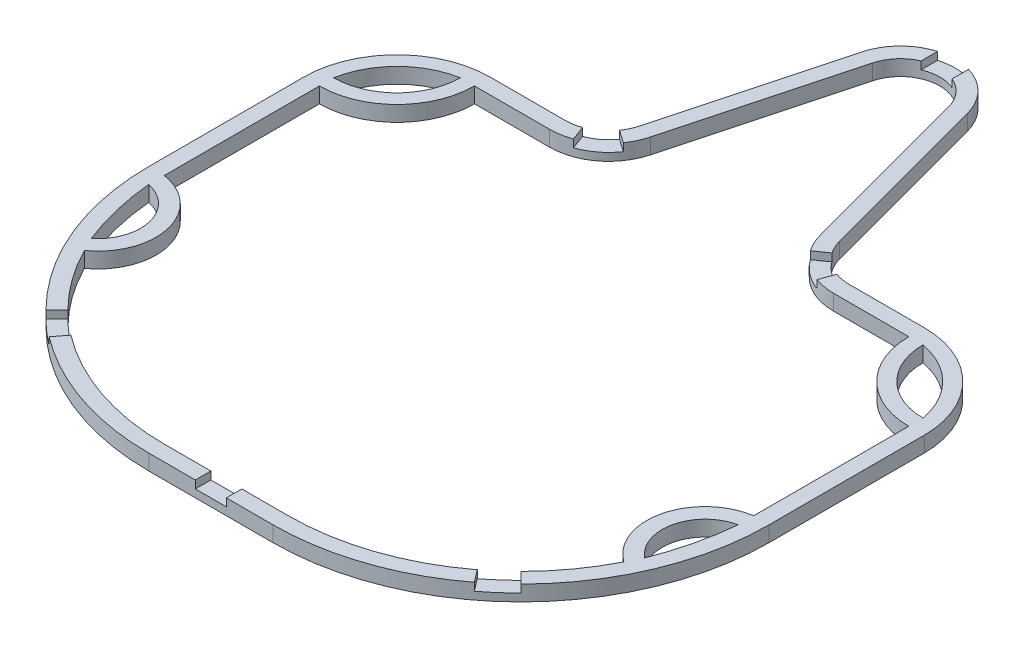
from build123d import *

# Parameters (mm, degrees)
BOSS_EXTRUDE1_DEPTH = 1.25
BOSS_EXTRUDE5_DEPTH = 2.5
SKETCH6_W           = 5
SKETCH6_H           = 4
CUT_EXTRUDE1_DEPTH  = 1.25
CUT_EXTRUDE2_DEPTH  = 2.5


with BuildPart() as part:
    # Sketch2 → Boss-Extrude1 (new body, symmetric)
    with BuildSketch(Plane(origin=(0, 0, 0), x_dir=(1, 0, 0), z_dir=(0, 1, 0))):
        with BuildLine():
            Line((-16.109808132, 32.688266684), (-8.537351427, 60.949059844))
            ThreePointArc((-8.537351427, 60.949059844), (0, 67.5), (8.537351427, 60.949059844))
            Line((8.537351427, 60.949059844), (16.109808132, 32.688266684))
            ThreePointArc((16.109808132, 32.688266684), (18.609958913, 28.946526618), (22.871288916, 27.5))
            Line((22.871288916, 27.5), (35, 27.5))
            ThreePointArc((35, 27.5), (45.606601718, 23.106601718), (50, 12.5))
            Line((50, 12.5), (50, -12.5))
            ThreePointArc((50, -12.5), (38.284271247, -40.784271247), (10, -52.5))
            Line((10, -52.5), (-10, -52.5))
            ThreePointArc((-10, -52.5), (-38.284271247, -40.784271247), (-50, -12.5))
            Line((-50, -12.5), (-50, 12.5))
            ThreePointArc((-50, 12.5), (-45.606601718, 23.106601718), (-35, 27.5))
            Line((-35, 27.5), (-22.871288916, 27.5))
            ThreePointArc((-22.871288916, 27.5), (-18.609958913, 28.946526618), (-16.109808132, 32.688266684))
        make_face()
        with BuildLine():
            Line((6.122536861, 60.302012231), (13.694993566, 32.041219072))
            ThreePointArc((13.694993566, 32.041219072), (17.08805534, 26.963143267), (22.871288916, 25))
            Line((22.871288916, 25), (35, 25))
            ThreePointArc((35, 25), (43.838834765, 21.338834765), (47.5, 12.5))
            Line((47.5, 12.5), (47.5, -12.5))
            ThreePointArc((47.5, -12.5), (36.516504294, -39.016504294), (10, -50))
            Line((10, -50), (-10, -50))
            ThreePointArc((-10, -50), (-36.516504294, -39.016504294), (-47.5, -12.5))
            Line((-47.5, -12.5), (-47.5, 12.5))
            ThreePointArc((-47.5, 12.5), (-43.838834765, 21.338834765), (-35, 25))
            Line((-35, 25), (-22.871288916, 25))
            ThreePointArc((-22.871288916, 25), (-17.08805534, 26.963143267), (-13.694993566, 32.041219072))
            Line((-13.694993566, 32.041219072), (-6.122536861, 60.302012231))
            ThreePointArc((-6.122536861, 60.302012231), (0, 65), (6.122536861, 60.302012231))
        make_face(mode=Mode.SUBTRACT)
    extrude(amount=BOSS_EXTRUDE1_DEPTH, both=True)

    # Sketch5 → Boss-Extrude5 (add)
    with BuildSketch(Plane(origin=(0, 1.25, 0), x_dir=(1, 0, 0), z_dir=(0, 1, 0))):
        with BuildLine():
            ThreePointArc((-47.5, 12.5), (-38.661165235, 16.161165235), (-35, 25))
            ThreePointArc((-35, 25), (-43.838834765, 21.338834765), (-47.5, 12.5))
        make_face()
        with BuildLine():
            ThreePointArc((35, 25), (38.661165235, 16.161165235), (47.5, 12.5))
            ThreePointArc((47.5, 12.5), (43.838834765, 21.338834765), (35, 25))
        make_face()
        with BuildLine():
            ThreePointArc((-47.5, -12.5), (-39.791585286, -19.595919329), (-43.473512014, -29.404851181))
            ThreePointArc((-43.473512014, -29.404851181), (-46.479492188, -21.188880811), (-47.5, -12.5))
        make_face()
        with BuildLine():
            ThreePointArc((47.5, -12.5), (39.791585286, -19.595919329), (43.473512014, -29.404851181))
            ThreePointArc((43.473512014, -29.404851181), (46.479492188, -21.188880811), (47.5, -12.5))
        make_face()
    extrude(amount=-BOSS_EXTRUDE5_DEPTH)

    # Sketch6 → Cut-Extrude1 (cut)
    with BuildSketch(Plane(origin=(0, 1.25, 0), x_dir=(1, 0, 0), z_dir=(0, 1, 0))):
        with Locations((0, 66.25)):
            Rectangle(SKETCH6_W, SKETCH6_H)
        with BuildLine():
            Line((-20.493193447, 27.916333701), (-19.643873637, 25.565024308))
            ThreePointArc((-19.643873637, 25.565024308), (-17.08805534, 26.963143267), (-15.076081678, 29.070014354))
            Line((-15.076081678, 29.070014354), (-17.127452004, 30.498957945))
            ThreePointArc((-17.127452004, 30.498957945), (-18.609958913, 28.946526618), (-20.493193447, 27.916333701))
        make_face()
        with BuildLine():
            Line((20.493193447, 27.916333701), (19.643873637, 25.565024308))
            ThreePointArc((19.643873637, 25.565024308), (17.08805534, 26.963143267), (15.076081678, 29.070014354))
            Line((15.076081678, 29.070014354), (17.127452004, 30.498957945))
            ThreePointArc((17.127452004, 30.498957945), (18.609958913, 28.946526618), (20.493193447, 27.916333701))
        make_face()
        with BuildLine():
            Line((-38.284271247, -40.784271247), (-36.516504294, -39.016504294))
            ThreePointArc((-36.516504294, -39.016504294), (-34.689746158, -40.725280064), (-32.753133619, -42.308470449))
            Line((-32.753133619, -42.308470449), (-34.270009194, -44.295701812))
            ThreePointArc((-34.270009194, -44.295701812), (-36.335729235, -42.606965401), (-38.284271247, -40.784271247))
        make_face()
        with BuildLine():
            Line((34.270009194, -44.295701812), (32.753133619, -42.308470449))
            ThreePointArc((32.753133619, -42.308470449), (34.689746158, -40.725280064), (36.516504294, -39.016504294))
            Line((36.516504294, -39.016504294), (38.284271247, -40.784271247))
            ThreePointArc((38.284271247, -40.784271247), (36.335729235, -42.606965401), (34.270009194, -44.295701812))
        make_face()
        with Locations((0, -51.5)):
            Rectangle(SKETCH6_W, SKETCH6_H)
    extrude(amount=-CUT_EXTRUDE1_DEPTH, mode=Mode.SUBTRACT)

    # Sketch7 → Cut-Extrude2 (cut)
    with BuildSketch(Plane(origin=(0, 1.25, 0), x_dir=(1, 0, 0), z_dir=(0, 1, 0))):
        with BuildLine():
            ThreePointArc((-47.5, 14.791666667), (-40.281618275, 17.781618275), (-37.291666667, 25))
            ThreePointArc((-37.291666667, 25), (-43.986148678, 21.486148678), (-47.5, 14.791666667))
        make_face()
        with BuildLine():
            ThreePointArc((37.291666667, 25), (43.986148678, 21.486148678), (47.5, 14.791666667))
            ThreePointArc((47.5, 14.791666667), (40.281618275, 17.781618275), (37.291666667, 25))
        make_face()
        with BuildLine():
            ThreePointArc((-44.600502093, -27.173283714), (-42.223551432, -20.175178049), (-47.5, -15))
            ThreePointArc((-47.5, -15), (-46.479492187, -21.188880811), (-44.600502093, -27.173283714))
        make_face()
        with BuildLine():
            ThreePointArc((47.5, -15), (46.479492187, -21.188880811), (44.600502093, -27.173283714))
            ThreePointArc((44.600502093, -27.173283714), (42.223551432, -20.175178049), (47.5, -15))
        make_face()
    extrude(amount=-CUT_EXTRUDE2_DEPTH, mode=Mode.SUBTRACT)


solid = part.part
